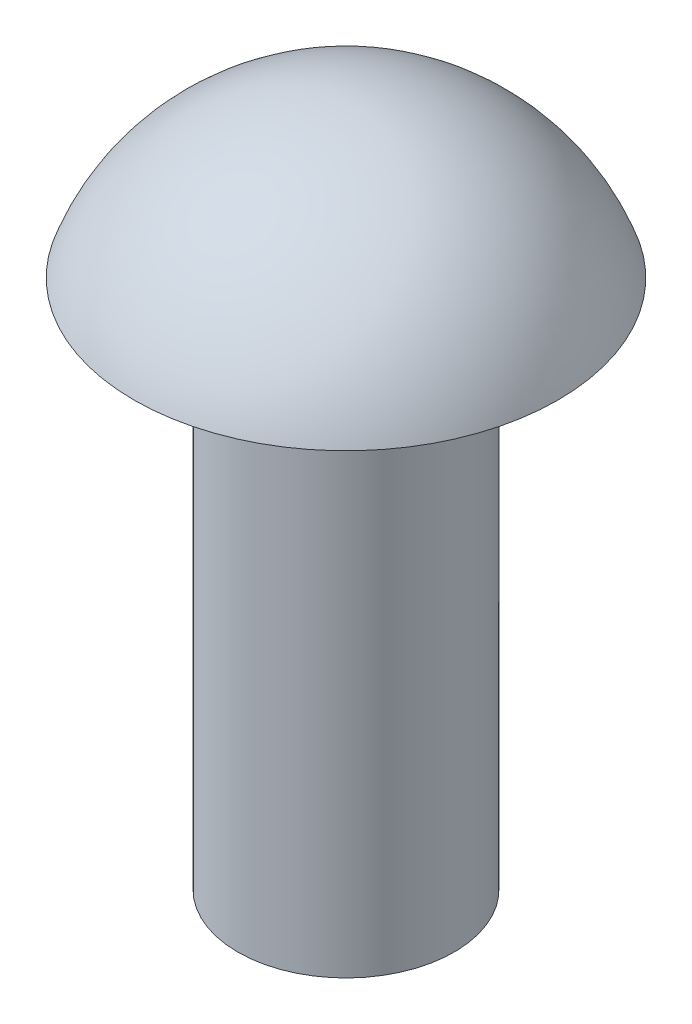
from build123d import *


with BuildPart() as part:
    # Sketch1 → Revolve2 (revolve)
    with BuildSketch(Plane(origin=(0, 0, 0), x_dir=(0, 0, -1), z_dir=(1, 0, 0))):
        with BuildLine():
            Line((0, -7.7), (1.225, -7.7))
            Line((1.225, -7.7), (1.225, -1.7))
            Line((1.225, -1.7), (2.4, -1.7))
            ThreePointArc((2.4, -1.7), (1.470544117, -0.468055364), (0, 0))
            Line((0, 0), (0, -7.7))
        make_face()
    revolve(axis=Axis((0, 0, 0), (0, -1, 0)))


solid = part.part
